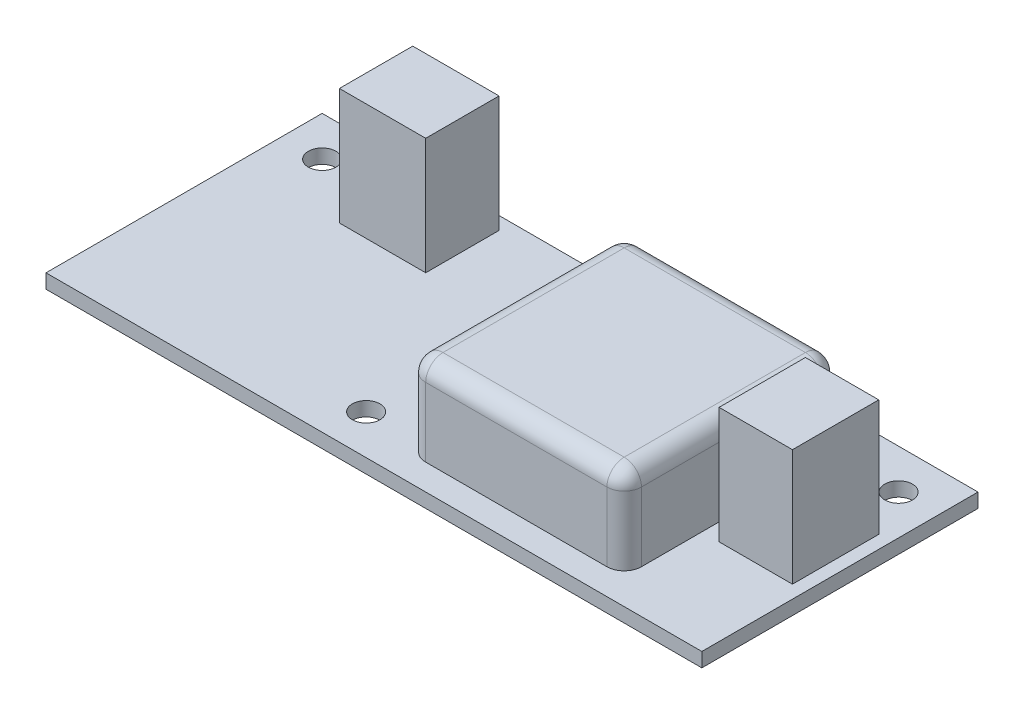
from build123d import *

# Parameters (mm, degrees)
SKETCH1_W                = 76
SKETCH1_H                = 32
BOSS_EXTRUDE1_DEPTH      = 1.65
M3_CLEARANCE_HOLE1_D     = 3.2
M3_CLEARANCE_HOLE1_DEPTH = 20
M3_CLEARANCE_HOLE1_TIP   = 0.96137699
SKETCH4_W                = 10
SKETCH4_H                = 8.5
SKETCH4_W_2              = 8.5
SKETCH4_H_2              = 10
BOSS_EXTRUDE2_DEPTH      = 13.5
SKETCH5_W                = 25
SKETCH5_H                = 25
BOSS_EXTRUDE3_DEPTH      = 10
FILLET1_R                = 2


with BuildPart() as part:
    # Sketch1 → Boss-Extrude1 (new body)
    with BuildSketch(Plane(origin=(0, 0, 0), x_dir=(1, 0, 0), z_dir=(0, 1, 0))):
        with Locations((38, 16)):
            Rectangle(SKETCH1_W, SKETCH1_H)
    extrude(amount=BOSS_EXTRUDE1_DEPTH)

    # M3 Clearance Hole1
    with Locations(Plane(origin=(0, 1.65, 0), x_dir=(1, 0, 0), z_dir=(0, 1, 0))):
        with Locations((71.4, 27.4), (32.5, 4.6), (4.6, 27.4)):
            Hole(M3_CLEARANCE_HOLE1_D / 2, depth=M3_CLEARANCE_HOLE1_DEPTH)
            with Locations((0, 0, -(M3_CLEARANCE_HOLE1_DEPTH + M3_CLEARANCE_HOLE1_TIP / 2))):  # 118° drill point
                Cone(0, M3_CLEARANCE_HOLE1_D / 2, M3_CLEARANCE_HOLE1_TIP, mode=Mode.SUBTRACT)

    # Sketch4 → Boss-Extrude2 (add)
    with BuildSketch(Plane(origin=(0, 1.65, 0), x_dir=(1, 0, 0), z_dir=(0, 1, 0))):
        with Locations((17, 26.25)):
            Rectangle(SKETCH4_W, SKETCH4_H)
        with Locations((70.25, 17)):
            Rectangle(SKETCH4_W_2, SKETCH4_H_2)
    extrude(amount=BOSS_EXTRUDE2_DEPTH)

    # Sketch5 → Boss-Extrude3 (add)
    with BuildSketch(Plane(origin=(0, 1.65, 0), x_dir=(1, 0, 0), z_dir=(0, 1, 0))):
        with Locations((51.5, 15.5)):
            Rectangle(SKETCH5_W, SKETCH5_H)
    extrude(amount=BOSS_EXTRUDE3_DEPTH)

    # Fillet1
    fillet1_edges = [part.edges().sort_by_distance(p)[0] for p in [
        (64, 6.65, -3),
        (64, 6.65, -28),
        (39, 6.65, -28),
        (39, 6.65, -3),
        (64, 11.65, -15.5),
        (51.5, 11.65, -28),
        (39, 11.65, -15.5),
        (51.5, 11.65, -3),
    ]]
    fillet(fillet1_edges, radius=FILLET1_R)


solid = part.part
